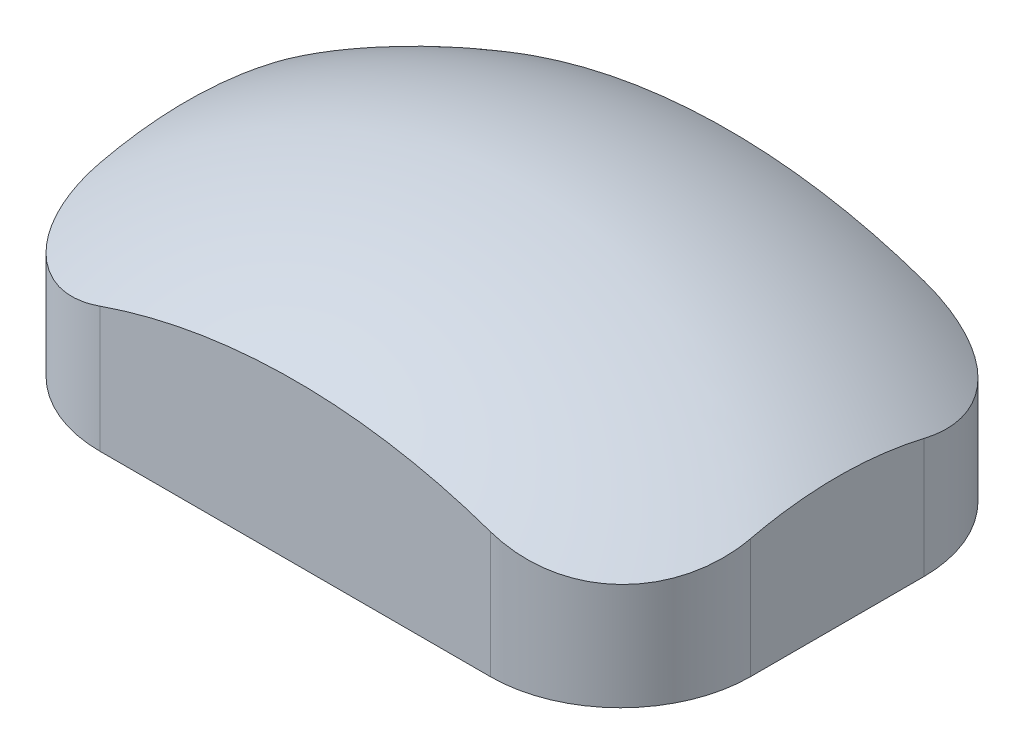
from build123d import *

# Parameters (mm, degrees)
ESQUISSE2_W        = 150
ESQUISSE2_H        = 100
BOSS_EXTRU_1_DEPTH = 50
CONG_1_R           = 30


with BuildPart() as part:
    # Esquisse2 → Boss.-Extru.1 (new body)
    with BuildSketch(Plane(origin=(0, 0, 0), x_dir=(1, 0, 0), z_dir=(0, 1, 0))):
        Rectangle(ESQUISSE2_W, ESQUISSE2_H)
    extrude(amount=BOSS_EXTRU_1_DEPTH)

    # Enlèvement de matière-Balayage1: sweep along a path in Esquisse3
    with BuildLine(Plane.XY) as enl_vement_de_mati_re_balayage1_path:
        ThreePointArc((111.803398875, 0), (0, 50), (-111.803398875, 0))
    # Esquisse4 → Enlèvement de matière-Balayage1 (sweep, cut)
    with BuildSketch(Plane(origin=(0, 0, 0), x_dir=(0, 0, -1), z_dir=(1, 0, 0))):
        with BuildLine():
            Line((-86.602540378, 0), (-86.602540378, 100))
            Line((-86.602540378, 100), (86.602540378, 100))
            Line((86.602540378, 100), (86.602540378, 0))
            ThreePointArc((86.602540378, 0), (0, 50), (-86.602540378, 0))
        make_face()
    sweep(path=enl_vement_de_mati_re_balayage1_path.line, mode=Mode.SUBTRACT)

    # Congé1
    cong_1_edges = [part.edges().sort_by_distance(p)[0] for p in [
        (-75, 7.086018511, 50),
        (-75, 7.086018511, -50),
        (75, 7.086018511, -50),
        (75, 7.086018511, 50),
    ]]
    fillet(cong_1_edges, radius=CONG_1_R)


solid = part.part
